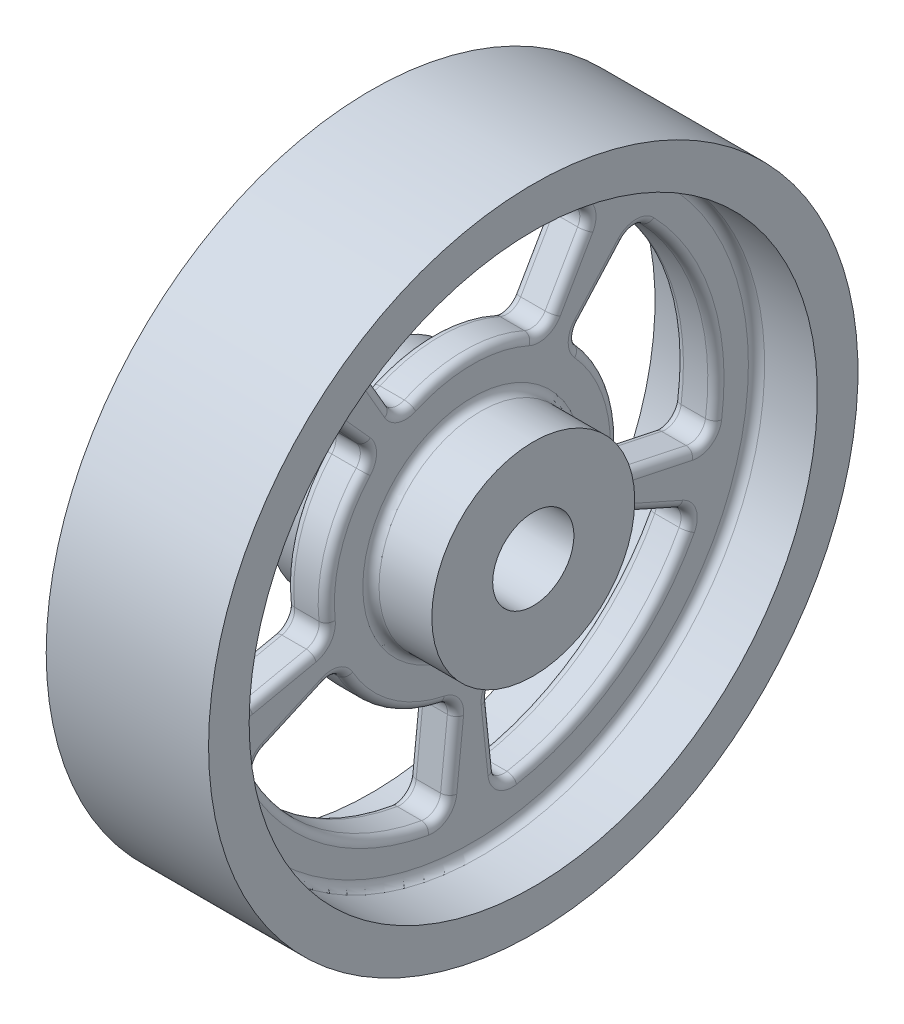
from build123d import *

# Parameters (mm, degrees)
REVOLVE1_ANGLE           = 360
CUT_EXTRUDE1_DEPTH       = 10
FILLET1_R                = 2
CIRPATTERN1_COUNT        = 5
FILLET1_OF_CIRPATTERN1_R = 2
FILLET2_R                = 1


with BuildPart() as part:
    # Sketch1 → Revolve1 (revolve, symmetric)
    with BuildSketch(Plane.XY) as revolve1_sk:
        Polygon((-2.5, 35), (-10, 35), (-10, 40), (10, 40), (10, 35), (2.5, 35), (2.5, 12.5), (10, 12.5), (10, 5), (-10, 5), (-10, 12.5), (-2.5, 12.5), align=None)
    revolve(axis=Axis((0, 0, 0), (1, 0, 0)), revolution_arc=REVOLVE1_ANGLE / 2)
    revolve(revolve1_sk.sketch, axis=Axis((0, 0, 0), (-1, 0, 0)), revolution_arc=REVOLVE1_ANGLE / 2)

    # Sketch2 → Cut-Extrude1 (cut)
    with BuildSketch(Plane(origin=(2.5, 0, 0), x_dir=(0, 0, -1), z_dir=(1, 0, 0))):
        with BuildLine():
            Line((-15, 25.980762114), (-9, 15.588457268))
            ThreePointArc((-9, 15.588457268), (0, 18), (9, 15.588457268))
            Line((9, 15.588457268), (15, 25.980762114))
            ThreePointArc((15, 25.980762114), (0, 30), (-15, 25.980762114))
        make_face()
    cut_extrude1 = extrude(amount=-CUT_EXTRUDE1_DEPTH, mode=Mode.SUBTRACT)

    # Fillet1
    fillet1_edges = [part.edges().sort_by_distance(p)[0] for p in [
        (0, 25.980762114, 15),
        (0, 25.980762114, -15),
        (0, 15.588457268, -9),
        (0, 15.588457268, 9),
    ]]
    fillet(fillet1_edges, radius=FILLET1_R)

    # CirPattern1: Cut-Extrude1 ×5 about axis
    cirpattern1_axis = Axis((0, 0, 0), (1, 0, 0))
    for i in range(1, CIRPATTERN1_COUNT):
        add(cut_extrude1.rotate(cirpattern1_axis, i * 360 / CIRPATTERN1_COUNT), mode=Mode.SUBTRACT)

    # Fillet1 of CirPattern1
    fillet1_of_cirpattern1_edges = [part.edges().sort_by_distance(p)[0] for p in [
        (0, -6.237350725, 29.344428022),
        (0, 22.294344764, 20.073918191),
        (0, 13.376606859, 12.044350914),
        (0, -3.742410435, 17.606656813),
        (0, -29.835656861, 3.135853898),
        (0, -12.202099292, 27.406363729),
        (0, -7.321259575, 16.443818238),
        (0, -17.901394117, 1.881512339),
        (0, -12.202099292, -27.406363729),
        (0, -29.835656861, -3.135853898),
        (0, -17.901394117, -1.881512339),
        (0, -7.321259575, -16.443818238),
        (0, 22.294344764, -20.073918191),
        (0, -6.237350725, -29.344428022),
        (0, -3.742410435, -17.606656813),
        (0, 13.376606859, -12.044350914),
    ]]
    fillet(fillet1_of_cirpattern1_edges, radius=FILLET1_OF_CIRPATTERN1_R)

    # Fillet2
    fillet2_edges = [part.edges().sort_by_distance(p)[0] for p in [
        (-2.5, 0, 35),
        (2.5, 0, 35),
        (2.5, 0, 12.5),
        (2.5, 17.771650383, -16.001665879),
        (-2.5, 17.771650383, -16.001665879),
        (2.5, 9.270509831, -28.531695489),
        (-2.5, 9.270509831, -28.531695489),
        (2.5, -4.972023962, -23.391533639),
        (-2.5, -4.972023962, -23.391533639),
        (2.5, 5.562305899, -17.119017293),
        (-2.5, 5.562305899, -17.119017293),
        (2.5, 21.416368191, -20.14086169),
        (-2.5, 21.416368191, -20.14086169),
        (2.5, -5.487704354, -28.882524769),
        (-2.5, -5.487704354, -28.882524769),
        (2.5, 13.445581763, -12.801825774),
        (-2.5, 13.445581763, -12.801825774),
        (2.5, -3.352979753, -18.260009279),
        (-2.5, -3.352979753, -18.260009279),
        (2.5, -9.726746619, -21.846630597),
        (-2.5, -9.726746619, -21.846630597),
        (2.5, -24.270509831, -17.633557569),
        (-2.5, -24.270509831, -17.633557569),
        (2.5, -23.783110394, -2.49970563),
        (-2.5, -23.783110394, -2.49970563),
        (2.5, -14.562305899, -10.580134541),
        (-2.5, -14.562305899, -10.580134541),
        (2.5, -12.537076026, -26.592045067),
        (-2.5, -12.537076026, -26.592045067),
        (2.5, -29.164707294, -3.706074009),
        (-2.5, -29.164707294, -3.706074009),
        (2.5, -8.020346559, -16.743489875),
        (-2.5, -8.020346559, -16.743489875),
        (2.5, -18.402428538, -2.453779941),
        (-2.5, -18.402428538, -2.453779941),
        (2.5, -23.783110394, 2.49970563),
        (-2.5, -23.783110394, 2.49970563),
        (2.5, -24.270509831, 17.633557569),
        (-2.5, -24.270509831, 17.633557569),
        (2.5, -9.726746619, 21.846630597),
        (-2.5, -9.726746619, 21.846630597),
        (2.5, -14.562305899, 10.580134541),
        (-2.5, -14.562305899, 10.580134541),
        (2.5, -29.164707294, 3.706074009),
        (-2.5, -29.164707294, 3.706074009),
        (2.5, -12.537076026, 26.592045067),
        (-2.5, -12.537076026, 26.592045067),
        (2.5, -18.402428538, 2.453779941),
        (-2.5, -18.402428538, 2.453779941),
        (2.5, -8.020346559, 16.743489875),
        (-2.5, -8.020346559, 16.743489875),
        (2.5, -4.972023962, 23.391533639),
        (-2.5, -4.972023962, 23.391533639),
        (2.5, 9.270509831, 28.531695489),
        (-2.5, 9.270509831, 28.531695489),
        (2.5, 17.771650383, 16.001665879),
        (-2.5, 17.771650383, 16.001665879),
        (2.5, 5.562305899, 17.119017293),
        (-2.5, 5.562305899, 17.119017293),
        (2.5, -5.487704354, 28.882524769),
        (-2.5, -5.487704354, 28.882524769),
        (2.5, 21.416368191, 20.14086169),
        (-2.5, 21.416368191, 20.14086169),
        (2.5, -3.352979753, 18.260009279),
        (-2.5, -3.352979753, 18.260009279),
        (2.5, 13.445581763, 12.801825774),
        (-2.5, 13.445581763, 12.801825774),
        (2.5, 20.710230592, 11.957057207),
        (-2.5, 20.710230592, 11.957057207),
        (2.5, 29.236747889, -6.72402951),
        (-2.5, 29.236747889, 6.72402951),
        (2.5, 20.710230592, -11.957057207),
        (-2.5, 20.710230592, -11.957057207),
        (2.5, 17.59809286, 3.782476396),
        (-2.5, 17.59809286, 3.782476396),
        (2.5, 25.773119483, 14.14430798),
        (-2.5, 25.773119483, 14.14430798),
        (2.5, 25.773119483, -14.14430798),
        (-2.5, 25.773119483, -14.14430798),
        (2.5, 16.330173087, 8.831526428),
        (-2.5, 16.330173087, 8.831526428),
        (2.5, 16.330173087, -8.831526428),
        (-2.5, 16.330173087, -8.831526428),
        (-2.5, 0, 12.5),
    ]]
    fillet(fillet2_edges, radius=FILLET2_R)


solid = part.part
